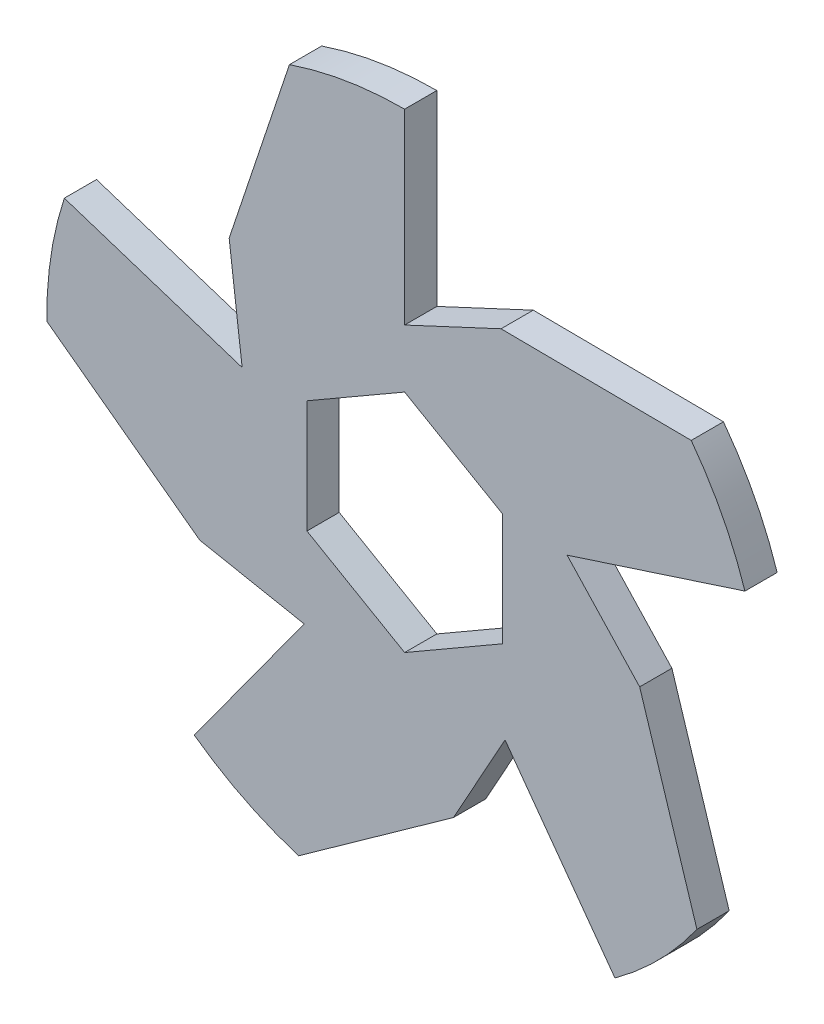
from build123d import *

# Parameters (mm, degrees)
RESSALTO_EXTRUS_O1_DEPTH = 5


with BuildPart() as part:
    # Esboço1 → Ressalto-extrusão1 (new body)
    with BuildSketch(Plane.XY):
        with BuildLine():
            Line((0, 26.5), (0, 55.5))
            ThreePointArc((0, 55.5), (-9.054313021, 54.756455471), (-17.86602118, 52.545744711))
            Line((-17.86602118, 52.545744711), (-27.213841848, 24.565961853))
            Line((-27.213841848, 24.565961853), (-25.202997682, 8.188950351))
            Line((-25.202997682, 8.188950351), (-52.783636654, 17.150443188))
            ThreePointArc((-52.783636654, 17.150443188), (-54.874420381, 8.309511893), (-55.494877077, -0.754067766))
            Line((-55.494877077, -0.754067766), (-31.773157713, -18.290601927))
            Line((-31.773157713, -18.290601927), (-15.576309186, -21.438950351))
            Line((-15.576309186, -21.438950351), (-32.622081502, -44.900443188))
            ThreePointArc((-32.622081502, -44.900443188), (-24.859943887, -49.620894691), (-16.431699055, -53.01178422))
            Line((-16.431699055, -53.01178422), (7.576950452, -35.870175519))
            Line((7.576950452, -35.870175519), (15.576309186, -21.438950351))
            Line((15.576309186, -21.438950351), (32.622081502, -44.900443188))
            ThreePointArc((32.622081502, -44.900443188), (39.5101301, -38.976911364), (45.339528568, -32.009016686))
            Line((45.339528568, -32.009016686), (36.455970623, -3.878385726))
            Line((36.455970623, -3.878385726), (25.202997682, 8.188950351))
            Line((25.202997682, 8.188950351), (52.783636654, 17.150443188))
            ThreePointArc((52.783636654, 17.150443188), (49.278547189, 25.531838691), (44.453068744, 33.229123961))
            Line((44.453068744, 33.229123961), (14.954078486, 33.473201319))
            Line((14.954078486, 33.473201319), (0, 26.5))
        make_face()
        Polygon((-15.15, 8.746856578), (0, 17.493713156), (15.15, 8.746856578), (15.15, -8.746856578), (0, -17.493713156), (-15.15, -8.746856578), align=None, mode=Mode.SUBTRACT)
    extrude(amount=RESSALTO_EXTRUS_O1_DEPTH)


solid = part.part
